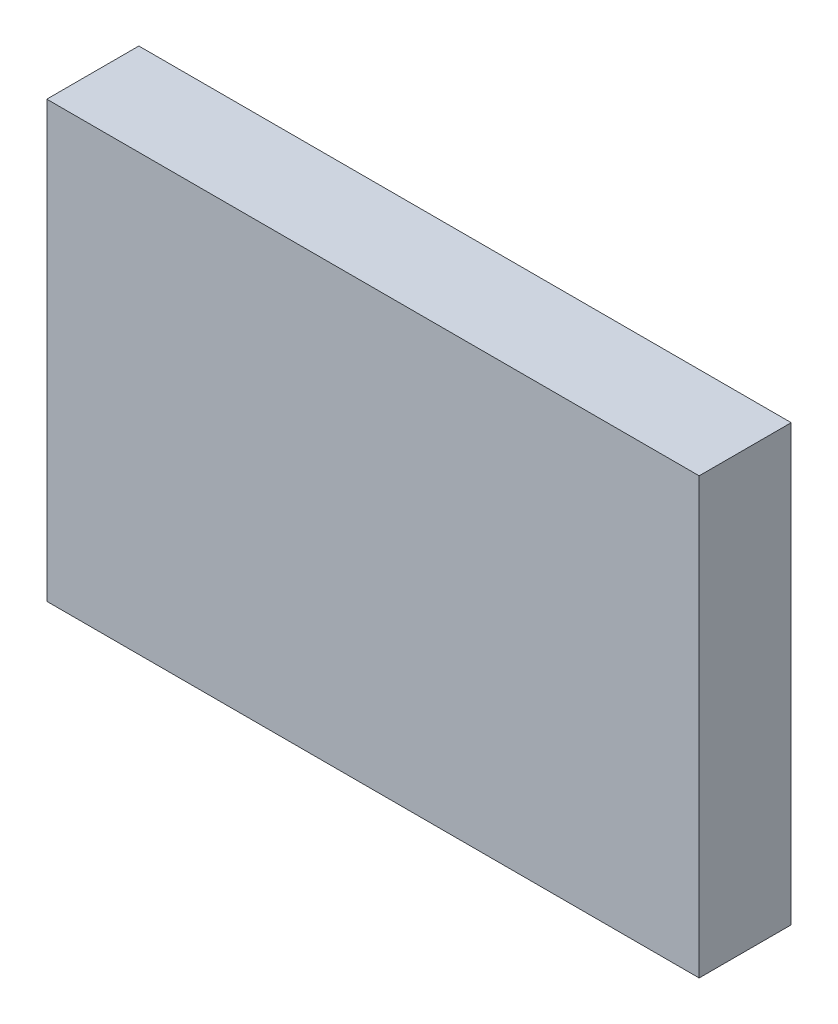
from build123d import *

# Parameters (mm, degrees)
SKETCH1_W           = 45
SKETCH1_H           = 30
BOSS_EXTRUDE1_DEPTH = 6.35


with BuildPart() as part:
    # Sketch1 → Boss-Extrude1 (new body)
    with BuildSketch(Plane.XY):
        with Locations((22.5, 15)):
            Rectangle(SKETCH1_W, SKETCH1_H)
    extrude(amount=BOSS_EXTRUDE1_DEPTH)


solid = part.part
